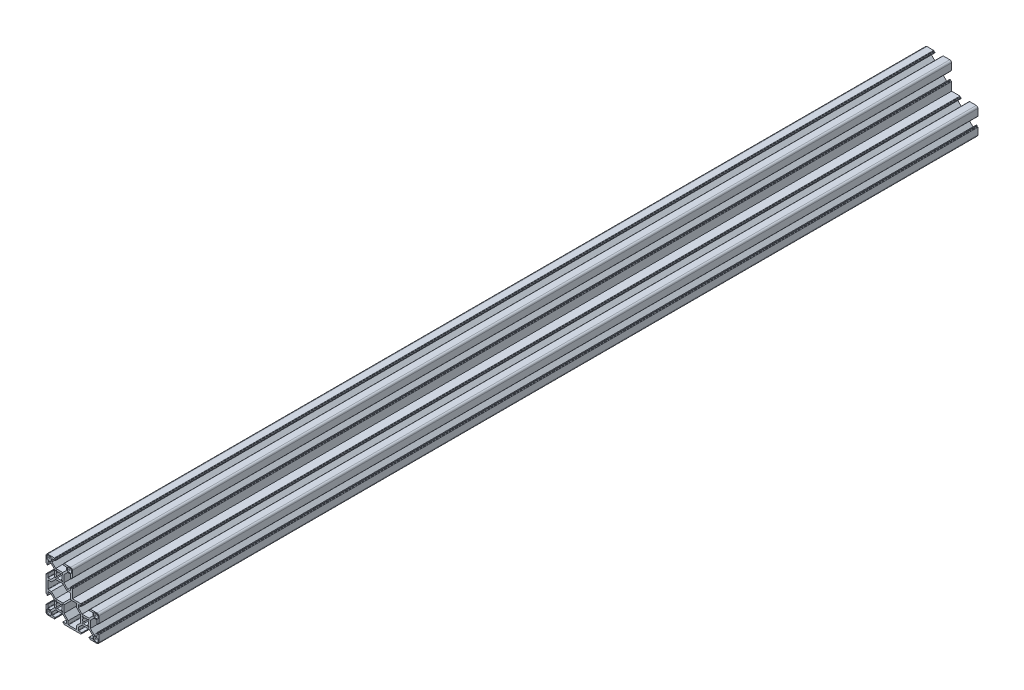
from build123d import *

# Parameters (mm, degrees)
EXTRUDE_1_DEPTH = 1000


with BuildPart() as part:
    # Эскиз1 → Бобышка-Вытянуть1 (new body)
    with BuildSketch(Plane.XY):
        with BuildLine():
            Line((-15, 38.25), (-15, 43))
            ThreePointArc((-15, 43), (-14.414213562, 44.414213562), (-13, 45))
            Line((-13, 45), (-8.25, 45))
            Line((-8.25, 45), (-5.5, 45))
            ThreePointArc((-5.5, 45), (-5.287867966, 44.912132034), (-5.2, 44.7))
            Line((-5.2, 44.7), (-5.2, 44.3))
            ThreePointArc((-5.2, 44.3), (-5.112132034, 44.087867966), (-4.9, 44))
            Line((-4.9, 44), (-4.4, 44))
            ThreePointArc((-4.4, 44), (-4.187867966, 43.912132034), (-4.1, 43.7))
            Line((-4.1, 43.7), (-4.1, 43.3))
            ThreePointArc((-4.1, 43.3), (-4.187867966, 43.087867966), (-4.4, 43))
            Line((-4.4, 43), (-7.95, 43))
            ThreePointArc((-7.95, 43), (-8.162132034, 42.912132034), (-8.25, 42.7))
            Line((-8.25, 42.7), (-8.25, 39.65))
            Line((-8.25, 39.65), (-4, 35.4))
            Line((-4, 35.4), (4, 35.4))
            Line((4, 35.4), (8.25, 39.65))
            Line((8.25, 39.65), (8.25, 42.7))
            ThreePointArc((8.25, 42.7), (8.162132034, 42.912132034), (7.95, 43))
            Line((7.95, 43), (4.4, 43))
            ThreePointArc((4.4, 43), (4.187867966, 43.087867966), (4.1, 43.3))
            Line((4.1, 43.3), (4.1, 43.7))
            ThreePointArc((4.1, 43.7), (4.187867966, 43.912132034), (4.4, 44))
            Line((4.4, 44), (4.9, 44))
            ThreePointArc((4.9, 44), (5.112132034, 44.087867966), (5.2, 44.3))
            Line((5.2, 44.3), (5.2, 44.7))
            ThreePointArc((5.2, 44.7), (5.287867966, 44.912132034), (5.5, 45))
            Line((5.5, 45), (8.25, 45))
            Line((8.25, 45), (13, 45))
            ThreePointArc((13, 45), (14.414213562, 44.414213562), (15, 43))
            Line((15, 43), (15, 38.25))
            Line((15, 38.25), (15, 35.5))
            ThreePointArc((15, 35.5), (14.912132034, 35.287867966), (14.7, 35.2))
            Line((14.7, 35.2), (14.3, 35.2))
            ThreePointArc((14.3, 35.2), (14.087867966, 35.112132034), (14, 34.9))
            Line((14, 34.9), (14, 34.4))
            ThreePointArc((14, 34.4), (13.912132034, 34.187867966), (13.7, 34.1))
            Line((13.7, 34.1), (13.3, 34.1))
            ThreePointArc((13.3, 34.1), (13.087867966, 34.187867966), (13, 34.4))
            Line((13, 34.4), (13, 37.95))
            ThreePointArc((13, 37.95), (12.912132034, 38.162132034), (12.7, 38.25))
            Line((12.7, 38.25), (9.65, 38.25))
            Line((9.65, 38.25), (5.4, 34))
            Line((5.4, 34), (5.4, 26))
            Line((5.4, 26), (9.65, 21.75))
            Line((9.65, 21.75), (12.7, 21.75))
            ThreePointArc((12.7, 21.75), (12.912132034, 21.837867966), (13, 22.05))
            Line((13, 22.05), (13, 25.6))
            ThreePointArc((13, 25.6), (13.087867966, 25.812132034), (13.3, 25.9))
            Line((13.3, 25.9), (13.7, 25.9))
            ThreePointArc((13.7, 25.9), (13.912132034, 25.812132034), (14, 25.6))
            Line((14, 25.6), (14, 25.1))
            ThreePointArc((14, 25.1), (14.087867966, 24.887867966), (14.3, 24.8))
            Line((14.3, 24.8), (14.7, 24.8))
            ThreePointArc((14.7, 24.8), (14.912132034, 24.712132034), (15, 24.5))
            Line((15, 24.5), (15, 21.75))
            Line((15, 21.75), (15, 15))
            Line((15, 15), (21.75, 15))
            Line((21.75, 15), (24.5, 15))
            ThreePointArc((24.5, 15), (24.712132034, 14.912132034), (24.8, 14.7))
            Line((24.8, 14.7), (24.8, 14.3))
            ThreePointArc((24.8, 14.3), (24.887867966, 14.087867966), (25.1, 14))
            Line((25.1, 14), (25.6, 14))
            ThreePointArc((25.6, 14), (25.812132034, 13.912132034), (25.9, 13.7))
            Line((25.9, 13.7), (25.9, 13.3))
            ThreePointArc((25.9, 13.3), (25.812132034, 13.087867966), (25.6, 13))
            Line((25.6, 13), (22.05, 13))
            ThreePointArc((22.05, 13), (21.837867966, 12.912132034), (21.75, 12.7))
            Line((21.75, 12.7), (21.75, 9.65))
            Line((21.75, 9.65), (26, 5.4))
            Line((26, 5.4), (34, 5.4))
            Line((34, 5.4), (38.25, 9.65))
            Line((38.25, 9.65), (38.25, 12.7))
            ThreePointArc((38.25, 12.7), (38.162132034, 12.912132034), (37.95, 13))
            Line((37.95, 13), (34.4, 13))
            ThreePointArc((34.4, 13), (34.187867966, 13.087867966), (34.1, 13.3))
            Line((34.1, 13.3), (34.1, 13.7))
            ThreePointArc((34.1, 13.7), (34.187867966, 13.912132034), (34.4, 14))
            Line((34.4, 14), (34.9, 14))
            ThreePointArc((34.9, 14), (35.112132034, 14.087867966), (35.2, 14.3))
            Line((35.2, 14.3), (35.2, 14.7))
            ThreePointArc((35.2, 14.7), (35.287867966, 14.912132034), (35.5, 15))
            Line((35.5, 15), (38.25, 15))
            Line((38.25, 15), (43, 15))
            ThreePointArc((43, 15), (44.414213562, 14.414213562), (45, 13))
            Line((45, 13), (45, 8.25))
            Line((45, 8.25), (45, 5.5))
            ThreePointArc((45, 5.5), (44.912132034, 5.287867966), (44.7, 5.2))
            Line((44.7, 5.2), (44.3, 5.2))
            ThreePointArc((44.3, 5.2), (44.087867966, 5.112132034), (44, 4.9))
            Line((44, 4.9), (44, 4.4))
            ThreePointArc((44, 4.4), (43.912132034, 4.187867966), (43.7, 4.1))
            Line((43.7, 4.1), (43.3, 4.1))
            ThreePointArc((43.3, 4.1), (43.087867966, 4.187867966), (43, 4.4))
            Line((43, 4.4), (43, 7.95))
            ThreePointArc((43, 7.95), (42.912132034, 8.162132034), (42.7, 8.25))
            Line((42.7, 8.25), (39.65, 8.25))
            Line((39.65, 8.25), (35.4, 4))
            Line((35.4, 4), (35.4, -4))
            Line((35.4, -4), (39.65, -8.25))
            Line((39.65, -8.25), (42.7, -8.25))
            ThreePointArc((42.7, -8.25), (42.912132034, -8.162132034), (43, -7.95))
            Line((43, -7.95), (43, -4.4))
            ThreePointArc((43, -4.4), (43.087867966, -4.187867966), (43.3, -4.1))
            Line((43.3, -4.1), (43.7, -4.1))
            ThreePointArc((43.7, -4.1), (43.912132034, -4.187867966), (44, -4.4))
            Line((44, -4.4), (44, -4.9))
            ThreePointArc((44, -4.9), (44.087867966, -5.112132034), (44.3, -5.2))
            Line((44.3, -5.2), (44.7, -5.2))
            ThreePointArc((44.7, -5.2), (44.912132034, -5.287867966), (45, -5.5))
            Line((45, -5.5), (45, -8.25))
            Line((45, -8.25), (45, -13))
            ThreePointArc((45, -13), (44.414213562, -14.414213562), (43, -15))
            Line((43, -15), (38.25, -15))
            Line((38.25, -15), (35.5, -15))
            ThreePointArc((35.5, -15), (35.287867966, -14.912132034), (35.2, -14.7))
            Line((35.2, -14.7), (35.2, -14.3))
            ThreePointArc((35.2, -14.3), (35.112132034, -14.087867966), (34.9, -14))
            Line((34.9, -14), (34.4, -14))
            ThreePointArc((34.4, -14), (34.187867966, -13.912132034), (34.1, -13.7))
            Line((34.1, -13.7), (34.1, -13.3))
            ThreePointArc((34.1, -13.3), (34.187867966, -13.087867966), (34.4, -13))
            Line((34.4, -13), (37.95, -13))
            ThreePointArc((37.95, -13), (38.162132034, -12.912132034), (38.25, -12.7))
            Line((38.25, -12.7), (38.25, -9.65))
            Line((38.25, -9.65), (34, -5.4))
            Line((34, -5.4), (26, -5.4))
            Line((26, -5.4), (21.75, -9.65))
            Line((21.75, -9.65), (21.75, -12.7))
            ThreePointArc((21.75, -12.7), (21.837867966, -12.912132034), (22.05, -13))
            Line((22.05, -13), (25.6, -13))
            ThreePointArc((25.6, -13), (25.812132034, -13.087867966), (25.9, -13.3))
            Line((25.9, -13.3), (25.9, -13.7))
            ThreePointArc((25.9, -13.7), (25.812132034, -13.912132034), (25.6, -14))
            Line((25.6, -14), (25.1, -14))
            ThreePointArc((25.1, -14), (24.887867966, -14.087867966), (24.8, -14.3))
            Line((24.8, -14.3), (24.8, -14.7))
            ThreePointArc((24.8, -14.7), (24.712132034, -14.912132034), (24.5, -15))
            Line((24.5, -15), (21.75, -15))
            Line((21.75, -15), (8.25, -15))
            Line((8.25, -15), (5.5, -15))
            ThreePointArc((5.5, -15), (5.287867966, -14.912132034), (5.2, -14.7))
            Line((5.2, -14.7), (5.2, -14.3))
            ThreePointArc((5.2, -14.3), (5.112132034, -14.087867966), (4.9, -14))
            Line((4.9, -14), (4.4, -14))
            ThreePointArc((4.4, -14), (4.187867966, -13.912132034), (4.1, -13.7))
            Line((4.1, -13.7), (4.1, -13.3))
            ThreePointArc((4.1, -13.3), (4.187867966, -13.087867966), (4.4, -13))
            Line((4.4, -13), (7.95, -13))
            ThreePointArc((7.95, -13), (8.162132034, -12.912132034), (8.25, -12.7))
            Line((8.25, -12.7), (8.25, -9.65))
            Line((8.25, -9.65), (4, -5.4))
            Line((4, -5.4), (-4, -5.4))
            Line((-4, -5.4), (-8.25, -9.65))
            Line((-8.25, -9.65), (-8.25, -12.7))
            ThreePointArc((-8.25, -12.7), (-8.162132034, -12.912132034), (-7.95, -13))
            Line((-7.95, -13), (-4.4, -13))
            ThreePointArc((-4.4, -13), (-4.187867966, -13.087867966), (-4.1, -13.3))
            Line((-4.1, -13.3), (-4.1, -13.7))
            ThreePointArc((-4.1, -13.7), (-4.187867966, -13.912132034), (-4.4, -14))
            Line((-4.4, -14), (-4.9, -14))
            ThreePointArc((-4.9, -14), (-5.112132034, -14.087867966), (-5.2, -14.3))
            Line((-5.2, -14.3), (-5.2, -14.7))
            ThreePointArc((-5.2, -14.7), (-5.287867966, -14.912132034), (-5.5, -15))
            Line((-5.5, -15), (-8.25, -15))
            Line((-8.25, -15), (-13, -15))
            ThreePointArc((-13, -15), (-14.414213562, -14.414213562), (-15, -13))
            Line((-15, -13), (-15, -8.25))
            Line((-15, -8.25), (-15, -5.5))
            ThreePointArc((-15, -5.5), (-14.912132034, -5.287867966), (-14.7, -5.2))
            Line((-14.7, -5.2), (-14.3, -5.2))
            ThreePointArc((-14.3, -5.2), (-14.087867966, -5.112132034), (-14, -4.9))
            Line((-14, -4.9), (-14, -4.4))
            ThreePointArc((-14, -4.4), (-13.912132034, -4.187867966), (-13.7, -4.1))
            Line((-13.7, -4.1), (-13.3, -4.1))
            ThreePointArc((-13.3, -4.1), (-13.087867966, -4.187867966), (-13, -4.4))
            Line((-13, -4.4), (-13, -7.95))
            ThreePointArc((-13, -7.95), (-12.912132034, -8.162132034), (-12.7, -8.25))
            Line((-12.7, -8.25), (-9.65, -8.25))
            Line((-9.65, -8.25), (-5.4, -4))
            Line((-5.4, -4), (-5.4, 4))
            Line((-5.4, 4), (-9.65, 8.25))
            Line((-9.65, 8.25), (-12.7, 8.25))
            ThreePointArc((-12.7, 8.25), (-12.912132034, 8.162132034), (-13, 7.95))
            Line((-13, 7.95), (-13, 4.4))
            ThreePointArc((-13, 4.4), (-13.087867966, 4.187867966), (-13.3, 4.1))
            Line((-13.3, 4.1), (-13.7, 4.1))
            ThreePointArc((-13.7, 4.1), (-13.912132034, 4.187867966), (-14, 4.4))
            Line((-14, 4.4), (-14, 4.9))
            ThreePointArc((-14, 4.9), (-14.087867966, 5.112132034), (-14.3, 5.2))
            Line((-14.3, 5.2), (-14.7, 5.2))
            ThreePointArc((-14.7, 5.2), (-14.912132034, 5.287867966), (-15, 5.5))
            Line((-15, 5.5), (-15, 8.25))
            Line((-15, 8.25), (-15, 21.75))
            Line((-15, 21.75), (-15, 24.5))
            ThreePointArc((-15, 24.5), (-14.912132034, 24.712132034), (-14.7, 24.8))
            Line((-14.7, 24.8), (-14.3, 24.8))
            ThreePointArc((-14.3, 24.8), (-14.087867966, 24.887867966), (-14, 25.1))
            Line((-14, 25.1), (-14, 25.6))
            ThreePointArc((-14, 25.6), (-13.912132034, 25.812132034), (-13.7, 25.9))
            Line((-13.7, 25.9), (-13.3, 25.9))
            ThreePointArc((-13.3, 25.9), (-13.087867966, 25.812132034), (-13, 25.6))
            Line((-13, 25.6), (-13, 22.05))
            ThreePointArc((-13, 22.05), (-12.912132034, 21.837867966), (-12.7, 21.75))
            Line((-12.7, 21.75), (-9.65, 21.75))
            Line((-9.65, 21.75), (-5.4, 26))
            Line((-5.4, 26), (-5.4, 34))
            Line((-5.4, 34), (-9.65, 38.25))
            Line((-9.65, 38.25), (-12.7, 38.25))
            ThreePointArc((-12.7, 38.25), (-12.912132034, 38.162132034), (-13, 37.95))
            Line((-13, 37.95), (-13, 34.4))
            ThreePointArc((-13, 34.4), (-13.087867966, 34.187867966), (-13.3, 34.1))
            Line((-13.3, 34.1), (-13.7, 34.1))
            ThreePointArc((-13.7, 34.1), (-13.912132034, 34.187867966), (-14, 34.4))
            Line((-14, 34.4), (-14, 34.9))
            ThreePointArc((-14, 34.9), (-14.087867966, 35.112132034), (-14.3, 35.2))
            Line((-14.3, 35.2), (-14.7, 35.2))
            ThreePointArc((-14.7, 35.2), (-14.912132034, 35.287867966), (-15, 35.5))
            Line((-15, 35.5), (-15, 38.25))
        make_face()
        with BuildLine():
            Line((-13.15, 43.95), (-10.05, 43.95))
            ThreePointArc((-10.05, 43.95), (-9.484314575, 43.715685425), (-9.25, 43.15))
            Line((-9.25, 43.15), (-9.25, 40.05))
            ThreePointArc((-9.25, 40.05), (-9.484314575, 39.484314575), (-10.05, 39.25))
            Line((-10.05, 39.25), (-13.15, 39.25))
            ThreePointArc((-13.15, 39.25), (-13.715685425, 39.484314575), (-13.95, 40.05))
            Line((-13.95, 40.05), (-13.95, 43.15))
            ThreePointArc((-13.95, 43.15), (-13.715685425, 43.715685425), (-13.15, 43.95))
        make_face(mode=Mode.SUBTRACT)
        with BuildLine():
            Line((13.15, 43.95), (10.05, 43.95))
            ThreePointArc((10.05, 43.95), (9.484314575, 43.715685425), (9.25, 43.15))
            Line((9.25, 43.15), (9.25, 40.05))
            ThreePointArc((9.25, 40.05), (9.484314575, 39.484314575), (10.05, 39.25))
            Line((10.05, 39.25), (13.15, 39.25))
            ThreePointArc((13.15, 39.25), (13.715685425, 39.484314575), (13.95, 40.05))
            Line((13.95, 40.05), (13.95, 43.15))
            ThreePointArc((13.95, 43.15), (13.715685425, 43.715685425), (13.15, 43.95))
        make_face(mode=Mode.SUBTRACT)
        with BuildLine():
            Line((-13.15, -13.95), (-10.05, -13.95))
            ThreePointArc((-10.05, -13.95), (-9.484314575, -13.715685425), (-9.25, -13.15))
            Line((-9.25, -13.15), (-9.25, -10.05))
            ThreePointArc((-9.25, -10.05), (-9.484314575, -9.484314575), (-10.05, -9.25))
            Line((-10.05, -9.25), (-13.15, -9.25))
            ThreePointArc((-13.15, -9.25), (-13.715685425, -9.484314575), (-13.95, -10.05))
            Line((-13.95, -10.05), (-13.95, -13.15))
            ThreePointArc((-13.95, -13.15), (-13.715685425, -13.715685425), (-13.15, -13.95))
        make_face(mode=Mode.SUBTRACT)
        with BuildLine():
            Line((43.95, -13.15), (43.95, -10.05))
            ThreePointArc((43.95, -10.05), (43.715685425, -9.484314575), (43.15, -9.25))
            Line((43.15, -9.25), (40.05, -9.25))
            ThreePointArc((40.05, -9.25), (39.484314575, -9.484314575), (39.25, -10.05))
            Line((39.25, -10.05), (39.25, -13.15))
            ThreePointArc((39.25, -13.15), (39.484314575, -13.715685425), (40.05, -13.95))
            Line((40.05, -13.95), (43.15, -13.95))
            ThreePointArc((43.15, -13.95), (43.715685425, -13.715685425), (43.95, -13.15))
        make_face(mode=Mode.SUBTRACT)
        with BuildLine():
            Line((43.15, 13.95), (40.05, 13.95))
            ThreePointArc((40.05, 13.95), (39.484314575, 13.715685425), (39.25, 13.15))
            Line((39.25, 13.15), (39.25, 10.05))
            ThreePointArc((39.25, 10.05), (39.484314575, 9.484314575), (40.05, 9.25))
            Line((40.05, 9.25), (43.15, 9.25))
            ThreePointArc((43.15, 9.25), (43.715685425, 9.484314575), (43.95, 10.05))
            Line((43.95, 10.05), (43.95, 13.15))
            ThreePointArc((43.95, 13.15), (43.715685425, 13.715685425), (43.15, 13.95))
        make_face(mode=Mode.SUBTRACT)
        with BuildLine():
            Line((-13, 10.6), (-13, 19.4))
            ThreePointArc((-13, 19.4), (-12.912132034, 19.612132034), (-12.7, 19.7))
            Line((-12.7, 19.7), (-8.871572875, 19.7))
            Line((-8.871572875, 19.7), (-4.071572875, 24.5))
            Line((-4.071572875, 24.5), (4.071572875, 24.5))
            Line((4.071572875, 24.5), (8.871572875, 19.7))
            Line((8.871572875, 19.7), (12.7, 19.7))
            ThreePointArc((12.7, 19.7), (12.912132034, 19.612132034), (13, 19.4))
            Line((13, 19.4), (13, 15))
            Line((13, 15), (13, 13))
            Line((13, 13), (15, 13))
            Line((15, 13), (19.4, 13))
            ThreePointArc((19.4, 13), (19.612132034, 12.912132034), (19.7, 12.7))
            Line((19.7, 12.7), (19.7, 8.871572875))
            Line((19.7, 8.871572875), (24.5, 4.071572875))
            Line((24.5, 4.071572875), (24.5, -4.071572875))
            Line((24.5, -4.071572875), (19.7, -8.871572875))
            Line((19.7, -8.871572875), (19.7, -12.7))
            ThreePointArc((19.7, -12.7), (19.612132034, -12.912132034), (19.4, -13))
            Line((19.4, -13), (10.6, -13))
            ThreePointArc((10.6, -13), (10.387867966, -12.912132034), (10.3, -12.7))
            Line((10.3, -12.7), (10.3, -8.871572875))
            Line((10.3, -8.871572875), (5.5, -4.071572875))
            Line((5.5, -4.071572875), (5.5, 4.3))
            Line((5.5, 4.3), (4.3, 5.5))
            Line((4.3, 5.5), (-4.071572875, 5.5))
            Line((-4.071572875, 5.5), (-8.871572875, 10.3))
            Line((-8.871572875, 10.3), (-12.7, 10.3))
            ThreePointArc((-12.7, 10.3), (-12.912132034, 10.387867966), (-13, 10.6))
        make_face(mode=Mode.SUBTRACT)
        with BuildLine():
            Line((3.075914498, 33.853731957), (1.983589953, 32.761407412))
            ThreePointArc((1.983589953, 32.761407412), (0, 33.4), (-1.983589953, 32.761407412))
            Line((-1.983589953, 32.761407412), (-3.075914498, 33.853731957))
            ThreePointArc((-3.075914498, 33.853731957), (-3.853731957, 33.853731957), (-3.853731957, 33.075914498))
            Line((-3.853731957, 33.075914498), (-2.761407412, 31.983589953))
            ThreePointArc((-2.761407412, 31.983589953), (-3.4, 30), (-2.761407412, 28.016410047))
            Line((-2.761407412, 28.016410047), (-3.853731957, 26.924085502))
            ThreePointArc((-3.853731957, 26.924085502), (-3.853731957, 26.146268043), (-3.075914498, 26.146268043))
            Line((-3.075914498, 26.146268043), (-1.983589953, 27.238592588))
            ThreePointArc((-1.983589953, 27.238592588), (0, 26.6), (1.983589953, 27.238592588))
            Line((1.983589953, 27.238592588), (3.075914498, 26.146268043))
            ThreePointArc((3.075914498, 26.146268043), (3.853731957, 26.146268043), (3.853731957, 26.924085502))
            Line((3.853731957, 26.924085502), (2.761407412, 28.016410047))
            ThreePointArc((2.761407412, 28.016410047), (3.4, 30), (2.761407412, 31.983589953))
            Line((2.761407412, 31.983589953), (3.853731957, 33.075914498))
            ThreePointArc((3.853731957, 33.075914498), (3.853731957, 33.853731957), (3.075914498, 33.853731957))
        make_face(mode=Mode.SUBTRACT)
        with BuildLine():
            Line((3.075914498, 3.853731957), (1.983589953, 2.761407412))
            ThreePointArc((1.983589953, 2.761407412), (0, 3.4), (-1.983589953, 2.761407412))
            Line((-1.983589953, 2.761407412), (-3.075914498, 3.853731957))
            ThreePointArc((-3.075914498, 3.853731957), (-3.853731957, 3.853731957), (-3.853731957, 3.075914498))
            Line((-3.853731957, 3.075914498), (-2.761407412, 1.983589953))
            ThreePointArc((-2.761407412, 1.983589953), (-3.4, 0), (-2.761407412, -1.983589953))
            Line((-2.761407412, -1.983589953), (-3.853731957, -3.075914498))
            ThreePointArc((-3.853731957, -3.075914498), (-3.853731957, -3.853731957), (-3.075914498, -3.853731957))
            Line((-3.075914498, -3.853731957), (-1.983589953, -2.761407412))
            ThreePointArc((-1.983589953, -2.761407412), (0, -3.4), (1.983589953, -2.761407412))
            Line((1.983589953, -2.761407412), (3.075914498, -3.853731957))
            ThreePointArc((3.075914498, -3.853731957), (3.853731957, -3.853731957), (3.853731957, -3.075914498))
            Line((3.853731957, -3.075914498), (2.761407412, -1.983589953))
            ThreePointArc((2.761407412, -1.983589953), (3.4, 0), (2.761407412, 1.983589953))
            Line((2.761407412, 1.983589953), (3.853731957, 3.075914498))
            ThreePointArc((3.853731957, 3.075914498), (3.853731957, 3.853731957), (3.075914498, 3.853731957))
        make_face(mode=Mode.SUBTRACT)
        with BuildLine():
            Line((33.075914498, 3.853731957), (31.983589953, 2.761407412))
            ThreePointArc((31.983589953, 2.761407412), (30, 3.4), (28.016410047, 2.761407412))
            Line((28.016410047, 2.761407412), (26.924085502, 3.853731957))
            ThreePointArc((26.924085502, 3.853731957), (26.146268043, 3.853731957), (26.146268043, 3.075914498))
            Line((26.146268043, 3.075914498), (27.238592588, 1.983589953))
            ThreePointArc((27.238592588, 1.983589953), (26.6, 0), (27.238592588, -1.983589953))
            Line((27.238592588, -1.983589953), (26.146268043, -3.075914498))
            ThreePointArc((26.146268043, -3.075914498), (26.146268043, -3.853731957), (26.924085502, -3.853731957))
            Line((26.924085502, -3.853731957), (28.016410047, -2.761407412))
            ThreePointArc((28.016410047, -2.761407412), (30, -3.4), (31.983589953, -2.761407412))
            Line((31.983589953, -2.761407412), (33.075914498, -3.853731957))
            ThreePointArc((33.075914498, -3.853731957), (33.853731957, -3.853731957), (33.853731957, -3.075914498))
            Line((33.853731957, -3.075914498), (32.761407412, -1.983589953))
            ThreePointArc((32.761407412, -1.983589953), (33.4, 0), (32.761407412, 1.983589953))
            Line((32.761407412, 1.983589953), (33.853731957, 3.075914498))
            ThreePointArc((33.853731957, 3.075914498), (33.853731957, 3.853731957), (33.075914498, 3.853731957))
        make_face(mode=Mode.SUBTRACT)
    extrude(amount=EXTRUDE_1_DEPTH)


solid = part.part
